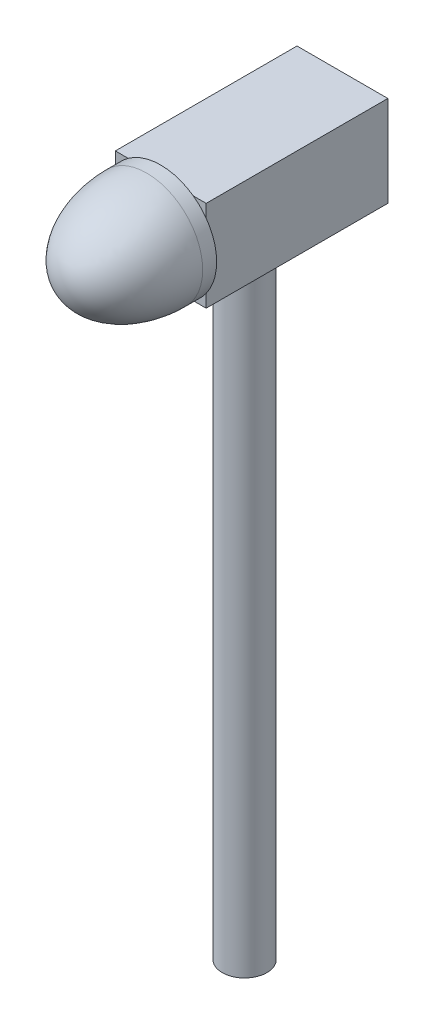
from build123d import *

# Parameters (mm, degrees)
SKETCH1_R           = 16
BOSS_EXTRUDE1_DEPTH = 450
SKETCH2_W           = 65
SKETCH2_H           = 130
BOSS_EXTRUDE2_DEPTH = 65
SKETCH3_R           = 40
BOSS_EXTRUDE3_DEPTH = 10
DOME1_FACE_RADIUS   = 40
DOME1_HEIGHT        = 60


with BuildPart() as part:
    # Sketch1 → Boss-Extrude1 (new body)
    with BuildSketch(Plane(origin=(0, 0, 0), x_dir=(1, 0, 0), z_dir=(0, 1, 0))):
        Circle(SKETCH1_R)
    extrude(amount=BOSS_EXTRUDE1_DEPTH)

    # Sketch2 → Boss-Extrude2 (add)
    with BuildSketch(Plane(origin=(0, 450, 0), x_dir=(1, 0, 0), z_dir=(0, 1, 0))):
        with Locations((0, 5)):
            Rectangle(SKETCH2_W, SKETCH2_H)
    extrude(amount=BOSS_EXTRUDE2_DEPTH)

    # Sketch3 → Boss-Extrude3 (add)
    with BuildSketch(Plane.XY.offset(60)):
        with Locations((0, 482.5)):
            Circle(SKETCH3_R)
    extrude(amount=BOSS_EXTRUDE3_DEPTH)

    # Dome1: an elliptical dome of height H over a round flat face of radius A is half a spheroid: the quarter ellipse of half axes A and H revolved about the face's axis
    with BuildSketch(Plane((0, 482.5, 70), x_dir=(0, 1, 0), z_dir=(1, 0, 0)), mode=Mode.PRIVATE) as dome1_quarter:
        Ellipse(DOME1_FACE_RADIUS, DOME1_HEIGHT)
        Rectangle(DOME1_FACE_RADIUS, DOME1_HEIGHT, align=(Align.MIN, Align.MIN), mode=Mode.INTERSECT)
    revolve(dome1_quarter.sketch, axis=Axis((0, 482.5, 70), (0, 0, 1)))


solid = part.part
